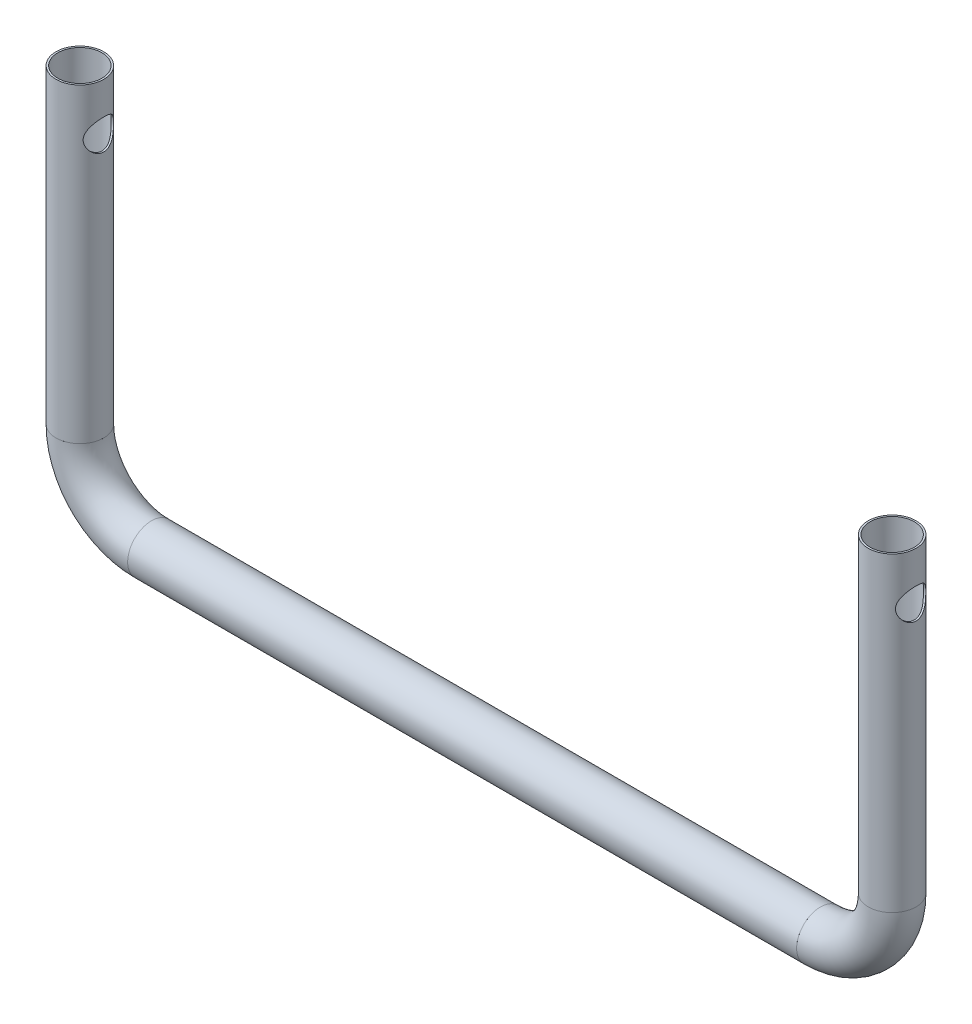
from build123d import *

# Parameters (mm, degrees)
SKETCH1_R                        = 10
SKETCH1_R_2                      = 9.25
ROUND_TUBE_DO20_DI18_5_1_DEPTH   = 130
SKETCH1_ON_SEGMENT_2_R           = 10
SKETCH1_ON_SEGMENT_2_R_2         = 9.25
ROUND_TUBE_DO20_DI18_5_1_2_ANGLE = 90
SKETCH1_ON_SEGMENT_3_R           = 10
SKETCH1_ON_SEGMENT_3_R_2         = 9.25
ROUND_TUBE_DO20_DI18_5_1_3_DEPTH = 280
SKETCH1_ON_SEGMENT_4_R           = 10
SKETCH1_ON_SEGMENT_4_R_2         = 9.25
ROUND_TUBE_DO20_DI18_5_1_4_ANGLE = 90
SKETCH1_ON_SEGMENT_5_R           = 10
SKETCH1_ON_SEGMENT_5_R_2         = 9.25
ROUND_TUBE_DO20_DI18_5_1_5_DEPTH = 130
SKETCH11_W                       = 6.35
SKETCH11_H                       = 400


with BuildPart() as part:
    # Sketch1 → Round_tube DO20_DI18_5(1) (new body)
    with BuildSketch(Plane.XZ):
        Circle(SKETCH1_R)
        Circle(SKETCH1_R_2, mode=Mode.SUBTRACT)
    extrude(amount=ROUND_TUBE_DO20_DI18_5_1_DEPTH)


with BuildPart() as body_2:
    # Sketch1 on segment 2 (carried to the start of arc 2) → Round_tube DO20_DI18_5_1 2 (revolve)
    with BuildSketch(Plane(origin=(30, -160, 0), x_dir=(0, -1, 0), z_dir=(-1, 0, 0))):
        Circle(SKETCH1_ON_SEGMENT_2_R)
        Circle(SKETCH1_ON_SEGMENT_2_R_2, mode=Mode.SUBTRACT)
    revolve(axis=Axis((30, -130, 0), (0, 0, -1)), revolution_arc=ROUND_TUBE_DO20_DI18_5_1_2_ANGLE)


with BuildPart() as body_3:
    # Sketch1 on segment 3 (carried to segment 3) → Round_tube DO20_DI18_5_1 3 (new body)
    with BuildSketch(Plane(origin=(30, -160, 0), x_dir=(0, 1, 0), z_dir=(1, 0, 0))):
        Circle(SKETCH1_ON_SEGMENT_3_R)
        Circle(SKETCH1_ON_SEGMENT_3_R_2, mode=Mode.SUBTRACT)
    extrude(amount=ROUND_TUBE_DO20_DI18_5_1_3_DEPTH)


with BuildPart() as body_4:
    # Sketch1 on segment 4 (carried to the start of arc 4) → Round_tube DO20_DI18_5_1 4 (revolve)
    with BuildSketch(Plane(origin=(340, -130, 0), x_dir=(1, 0, 0), z_dir=(0, -1, 0))):
        Circle(SKETCH1_ON_SEGMENT_4_R)
        Circle(SKETCH1_ON_SEGMENT_4_R_2, mode=Mode.SUBTRACT)
    revolve(axis=Axis((310, -130, 0), (0, 0, -1)), revolution_arc=ROUND_TUBE_DO20_DI18_5_1_4_ANGLE)


with BuildPart() as body_5:
    # Sketch1 on segment 5 (carried to segment 5) → Round_tube DO20_DI18_5_1 5 (new body)
    with BuildSketch(Plane(origin=(340, 0, 0), x_dir=(1, 0, 0), z_dir=(0, -1, 0))):
        Circle(SKETCH1_ON_SEGMENT_5_R)
        Circle(SKETCH1_ON_SEGMENT_5_R_2, mode=Mode.SUBTRACT)
    extrude(amount=ROUND_TUBE_DO20_DI18_5_1_5_DEPTH)


with BuildPart() as f_12_0mm_dowel_hole2_tool:
    # Sketch11 → Ø12.0mm Dowel Hole2 (revolve)
    with BuildSketch(Plane(origin=(-50, -20, 0), x_dir=(0, 0, 1), z_dir=(0, 1, 0))):
        with Locations((3.175, 200)):
            Rectangle(SKETCH11_W, SKETCH11_H)
    revolve(axis=Axis((-56.35, -20, 0), (1, 0, 0)))


with BuildPart() as part_1:
    add(part.part)

    # Ø12.0mm Dowel Hole2: cut by f_12_0mm_dowel_hole2_tool
    add(f_12_0mm_dowel_hole2_tool.part, mode=Mode.SUBTRACT)


with BuildPart() as body_5_1:
    add(body_5.part)

    # Ø12.0mm Dowel Hole2: cut by f_12_0mm_dowel_hole2_tool
    add(f_12_0mm_dowel_hole2_tool.part, mode=Mode.SUBTRACT)


solid = Compound([body_2.part, body_3.part, body_4.part, part_1.part, body_5_1.part])
